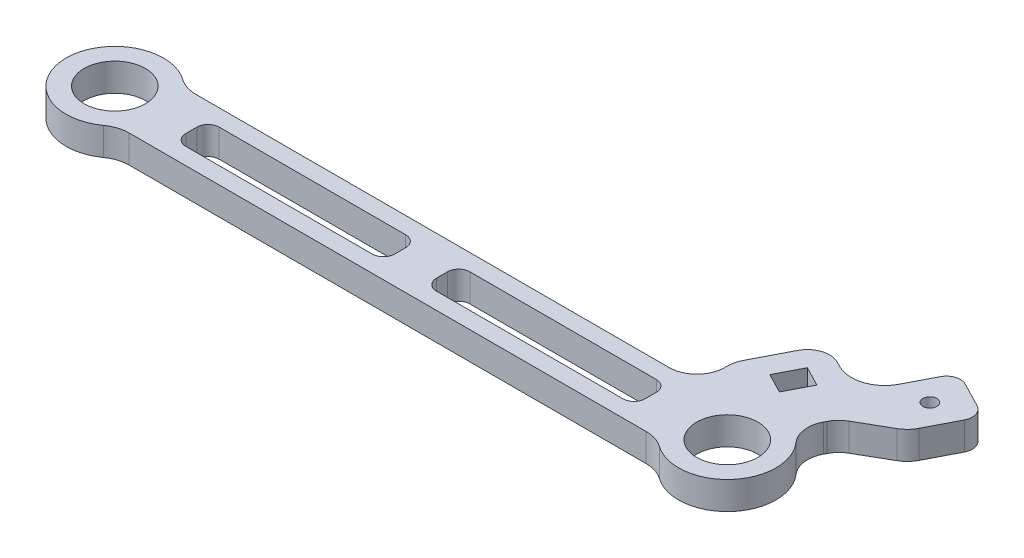
from build123d import *

# Parameters (mm, degrees)
SKETCH1_W           = 75
SKETCH1_H           = 12
SKETCH1_R           = 11
SKETCH1_R_2         = 2.5
BOSS_EXTRUDE1_DEPTH = 10
FILLET1_R           = 4
FILLET2_R           = 12
FILLET3_R           = 10


with BuildPart() as part:
    # Sketch1 → Boss-Extrude1 (new body)
    with BuildSketch(Plane(origin=(0, 0, 0), x_dir=(1, 0, 0), z_dir=(0, 1, 0))):
        with BuildLine():
            ThreePointArc((12.737739203, 12), (-17.5, 0), (12.737739203, -12))
            Line((12.737739203, -12), (207.262260797, -12))
            ThreePointArc((207.262260797, -12), (233.974449241, -10.533981603), (228.029081208, 15.549400469))
            Line((228.029081208, 15.549400469), (233.534736894, 26.211846505))
            Line((233.534736894, 26.211846505), (249.534736894, 35.402238979))
            Line((249.534736894, 35.402238979), (256.413650124, 48.724183776))
            ThreePointArc((256.413650124, 48.724183776), (256.734536929, 52.537540906), (254.264987478, 55.460892826))
            Line((254.264987478, 55.460892826), (245.379615782, 60.048939231))
            ThreePointArc((245.379615782, 60.048939231), (241.566258652, 60.369826035), (238.642906731, 57.900276585))
            Line((238.642906731, 57.900276585), (233.596055686, 48.126367719))
            ThreePointArc((233.596055686, 48.126367719), (226.580011076, 42.199449038), (217.427953964, 42.969577368))
            Line((217.427953964, 42.969577368), (215.650879625, 43.887186649))
            ThreePointArc((215.650879625, 43.887186649), (209.549508217, 44.400605536), (204.872145144, 40.449326415))
            Line((204.872145144, 40.449326415), (197.072466256, 25.344194531))
            Line((197.072466256, 25.344194531), (197.072466256, 12))
            Line((197.072466256, 12), (12.737739203, 12))
        make_face()
        with Locations((65, 0)):
            Rectangle(SKETCH1_W, SKETCH1_H, mode=Mode.SUBTRACT)
        with Locations((155, 0)):
            Rectangle(SKETCH1_W, SKETCH1_H, mode=Mode.SUBTRACT)
        Circle(SKETCH1_R, mode=Mode.SUBTRACT)
        with Locations((244.775450585, 47.981007162)):
            Circle(SKETCH1_R_2, mode=Mode.SUBTRACT)
        Polygon((207.392396097, 27.893517595), (211.980442501, 36.778889292), (219.088739859, 33.108452168), (214.500693454, 24.223080471), align=None, mode=Mode.SUBTRACT)
        with Locations((220, 0)):
            Circle(SKETCH1_R, mode=Mode.SUBTRACT)
    extrude(amount=BOSS_EXTRUDE1_DEPTH)

    # Fillet1
    fillet1_edges = [part.edges().sort_by_distance(p)[0] for p in [
        (27.5, 5, -6),
        (27.5, 5, 6),
        (102.5, 5, 6),
        (102.5, 5, -6),
        (117.5, 5, -6),
        (117.5, 5, 6),
        (192.5, 5, 6),
        (192.5, 5, -6),
    ]]
    fillet(fillet1_edges, radius=FILLET1_R)

    # Fillet2
    fillet2_edges = [part.edges().sort_by_distance(p)[0] for p in [
        (12.737739203, 5, 12),
        (12.737739203, 5, -12),
        (207.262260797, 5, 12),
    ]]
    fillet(fillet2_edges, radius=FILLET2_R)

    # Fillet3
    fillet3_edges = [part.edges().sort_by_distance(p)[0] for p in [
        (197.072466256, 5, -12),
        (197.072466256, 5, -25.344194531),
        (249.534736894, 5, -35.402238979),
        (233.534736894, 5, -26.211846505),
        (228.029081208, 5, -15.549400469),
    ]]
    fillet(fillet3_edges, radius=FILLET3_R)


solid = part.part
